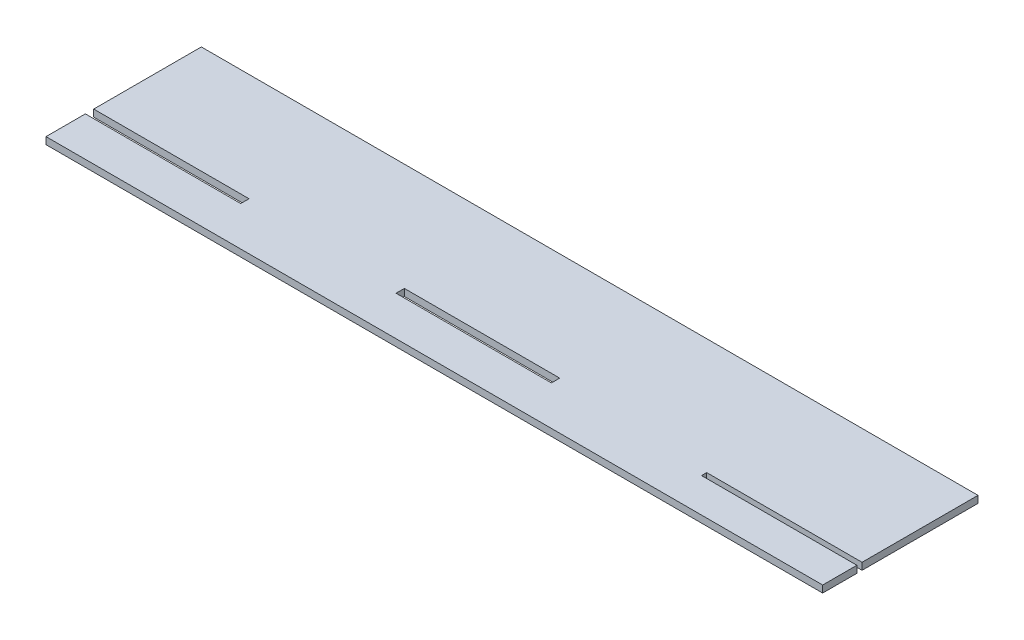
from build123d import *

# Parameters (mm, degrees)
SKETCH1_W           = 60
SKETCH1_H           = 3.218
BOSS_EXTRUDE1_DEPTH = 2.7


with BuildPart() as part:
    # Sketch1 → Boss-Extrude1 (new body)
    with BuildSketch(Plane(origin=(0, 0, 0), x_dir=(1, 0, 0), z_dir=(0, 1, 0))):
        Polygon((-150, -14.79), (-90, -14.79), (-90, -11.572), (-150, -11.572), (-150, 30), (150, 30), (150, -14.79), (90, -14.79), (90, -16.782), (150, -16.782), (150, -30), (-150, -30), align=None)
        with Locations((0, -13.181)):
            Rectangle(SKETCH1_W, SKETCH1_H, mode=Mode.SUBTRACT)
    extrude(amount=BOSS_EXTRUDE1_DEPTH)


solid = part.part
